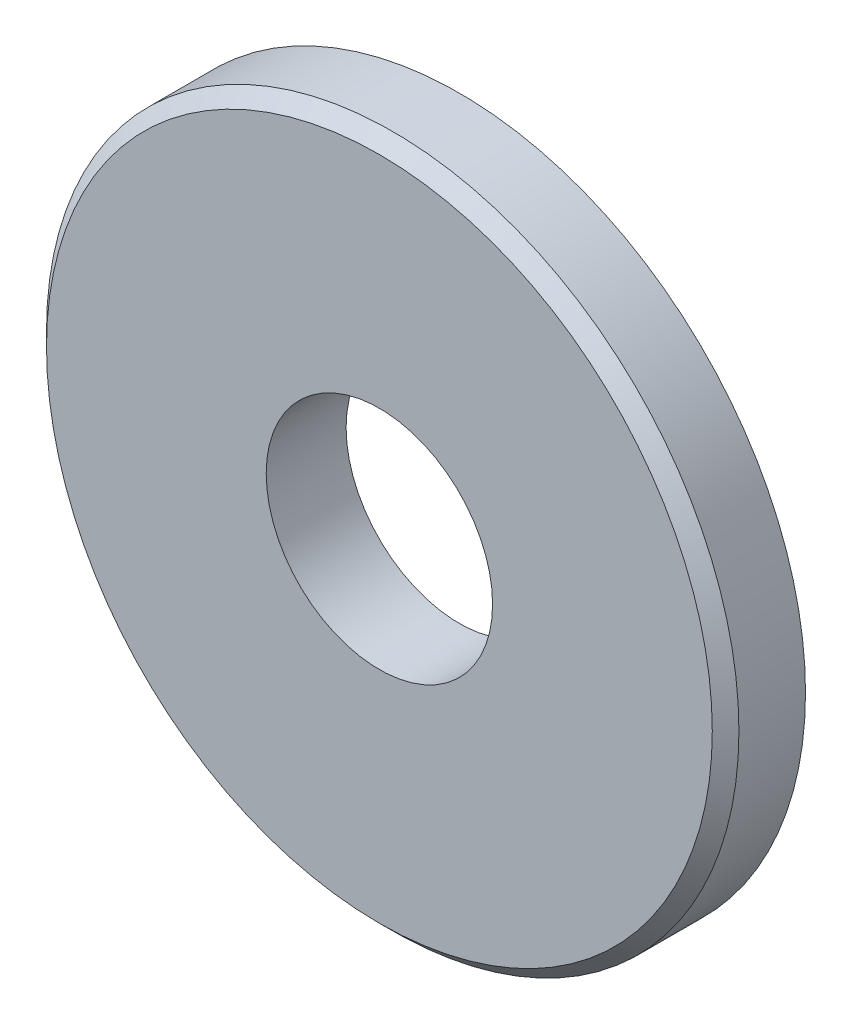
from build123d import *

# Parameters (mm, degrees)
CROQUIS1_R              = 13
CROQUIS1_R_2            = 4.25
SALIENTE_EXTRUIR1_DEPTH = 3
CHAFL_N1_SIZE           = 0.5


with BuildPart() as part:
    # Croquis1 → Saliente-Extruir1 (new body)
    with BuildSketch(Plane.XY):
        Circle(CROQUIS1_R)
        Circle(CROQUIS1_R_2, mode=Mode.SUBTRACT)
    extrude(amount=SALIENTE_EXTRUIR1_DEPTH)

    # Chaflán1
    chafl_n1_edges = [part.edges().sort_by_distance(p)[0] for p in [
        (-13, 0, 3),
    ]]
    chamfer(chafl_n1_edges, length=CHAFL_N1_SIZE)


solid = part.part
